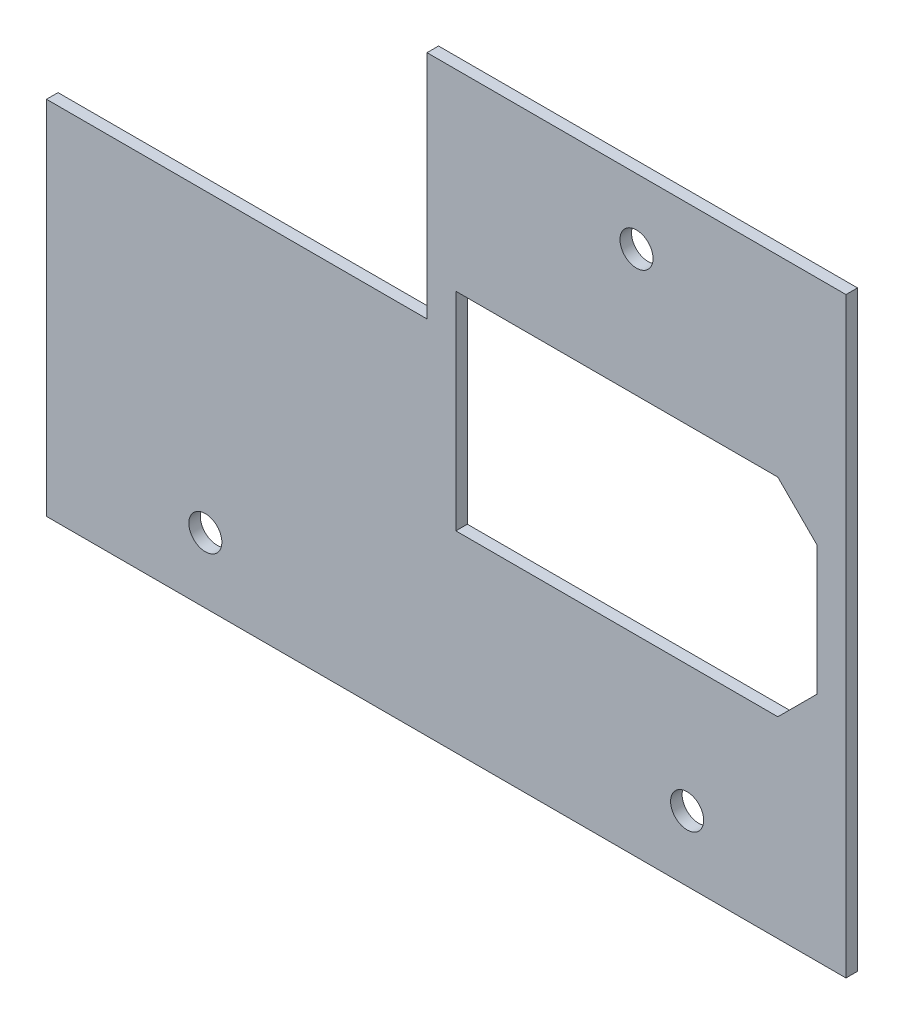
from build123d import *

# Parameters (mm, degrees)
BOSS_EXTRU_1_DEPTH      = 1.5
D_GAGEMENT_M41_D        = 4.3
D_GAGEMENT_M41_DEPTH    = 24
ENL_V_MAT_EXTRU_1_DEPTH = 2.5


with BuildPart() as part:
    # Esquisse1 → Boss.-Extru.1 (new body)
    with BuildSketch(Plane.XY.offset(-20)):
        Polygon((148.003126518, 65.528940229), (148.003126518, -11.471059771), (44, -11.471059771), (44, 35.528940229), (93.499999998, 35.528940229), (93.499999998, 65.528940229), align=None)
    extrude(amount=-BOSS_EXTRU_1_DEPTH)

    # Dégagement M41
    with Locations(Plane(origin=(0, 0, -21.5), x_dir=(-1, 0, 0), z_dir=(0, 0, -1))):
        with Locations((-120.751563258, 57.028940229), (-127.339384783, -2.971059771), (-64.663741735, -2.971059771)):
            Hole(D_GAGEMENT_M41_D / 2, depth=D_GAGEMENT_M41_DEPTH)

    # Esquisse5 → Enlèv. mat.-Extru.1 (cut, through all)
    with BuildSketch(Plane(origin=(0, 0, -21.5), x_dir=(-1, 0, 0), z_dir=(0, 0, -1))):
        Polygon((-97.251563258, 40.528940229), (-139.139101481, 40.528940229), (-144.251563258, 35.416478452), (-144.251563258, 18.641402007), (-139.139101481, 13.528940229), (-97.251563258, 13.528940229), align=None)
    extrude(amount=-ENL_V_MAT_EXTRU_1_DEPTH, mode=Mode.SUBTRACT)


solid = part.part
